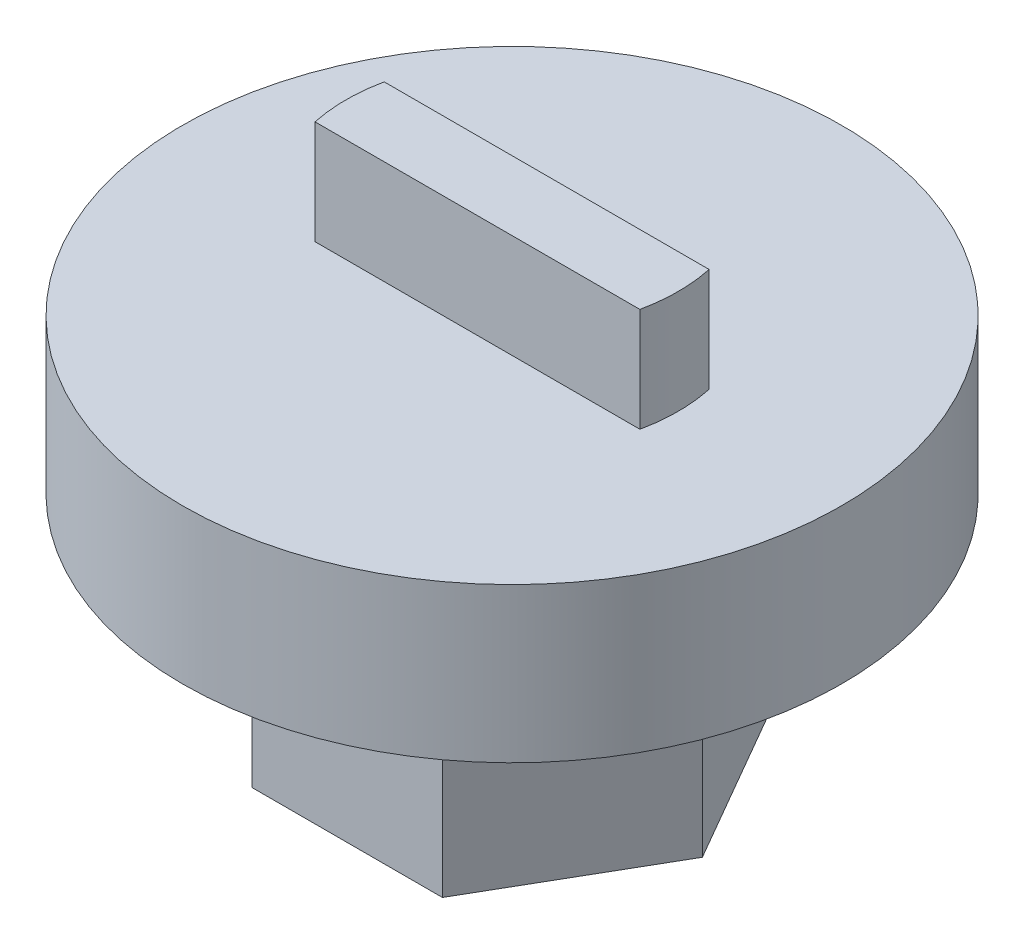
from build123d import *

# Parameters (mm, degrees)
BOSS_EXTRUDE1_DEPTH = 3.175
SKETCH2_R           = 4.7625
BOSS_EXTRUDE2_DEPTH = 2.23012
BOSS_EXTRUDE3_DEPTH = 1.5


with BuildPart() as part:
    # Sketch1 → Boss-Extrude1 (new body)
    with BuildSketch(Plane(origin=(0, 0, 0), x_dir=(1, 0, 0), z_dir=(0, 1, 0))):
        Polygon((1.374815329, 2.38125), (-1.374815329, 2.38125), (-2.749630657, 0), (-1.374815329, -2.38125), (1.374815329, -2.38125), (2.749630657, 0), align=None)
    extrude(amount=BOSS_EXTRUDE1_DEPTH)

    # Sketch2 → Boss-Extrude2 (add)
    with BuildSketch(Plane(origin=(0, 3.175, 0), x_dir=(1, 0, 0), z_dir=(0, 1, 0))):
        Circle(SKETCH2_R)
    extrude(amount=BOSS_EXTRUDE2_DEPTH)

    # Sketch3 → Boss-Extrude3 (add)
    with BuildSketch(Plane(origin=(0, 5.40512, 0), x_dir=(1, 0, 0), z_dir=(0, 1, 0))):
        with BuildLine():
            Line((-2.347338919, 0.5), (2.347338919, 0.5))
            ThreePointArc((2.347338919, 0.5), (2.4, 0), (2.347338919, -0.5))
            Line((2.347338919, -0.5), (-2.347338919, -0.5))
            ThreePointArc((-2.347338919, -0.5), (-2.4, 0), (-2.347338919, 0.5))
        make_face()
    extrude(amount=BOSS_EXTRUDE3_DEPTH)


solid = part.part
